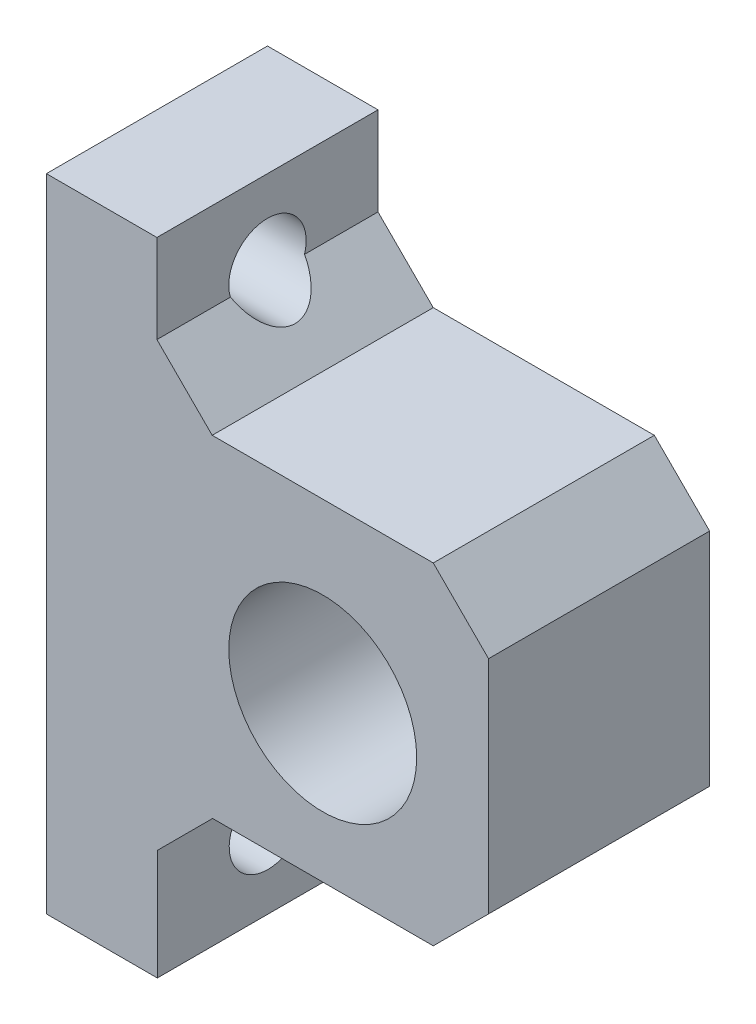
from build123d import *

# Parameters (mm, degrees)
SKETCH1_R           = 8.5
BOSS_EXTRUDE1_DEPTH = 20
CHAMFER1_SIZE       = 5
SKETCH2_R           = 3.5
CUT_EXTRUDE1_DEPTH  = 20
LPATTERN1_COUNT     = 200
LPATTERN1_PITCH     = 44


with BuildPart() as part:
    # Sketch1 → Boss-Extrude1 (new body)
    with BuildSketch(Plane.XY):
        Polygon((3.696498054, -34.435797665), (3.696498054, -19.435797665), (33.659197457, -19.435797665), (33.659197457, 10.564202335), (3.659197457, 10.564202335), (3.659197457, 23.564202335), (-6.340802543, 23.564202335), (-6.340802543, -34.435797665), align=None)
        with Locations((18.659197457, -5.435797665)):
            Circle(SKETCH1_R, mode=Mode.SUBTRACT)
    extrude(amount=BOSS_EXTRUDE1_DEPTH)

    # Chamfer1
    chamfer1_edges = [part.edges().sort_by_distance(p)[0] for p in [
        (3.659197457, 10.564202335, 10),
        (33.659197457, 10.564202335, 10),
        (33.659197457, -19.435797665, 10),
        (3.696498054, -19.435797665, 10),
    ]]
    chamfer(chamfer1_edges, length=CHAMFER1_SIZE)

    # Sketch2 → Cut-Extrude1 (cut)
    with BuildSketch(Plane.ZY.offset(6.340802543)):
        with Locations((10, 16.564202335)):
            Circle(SKETCH2_R)
    cut_extrude1 = extrude(amount=-CUT_EXTRUDE1_DEPTH, mode=Mode.SUBTRACT)

    # LPattern1: Cut-Extrude1 ×200
    with Locations(*[(0, -i * LPATTERN1_PITCH, 0) for i in range(1, LPATTERN1_COUNT)]):
        add(cut_extrude1, mode=Mode.SUBTRACT)


solid = part.part
